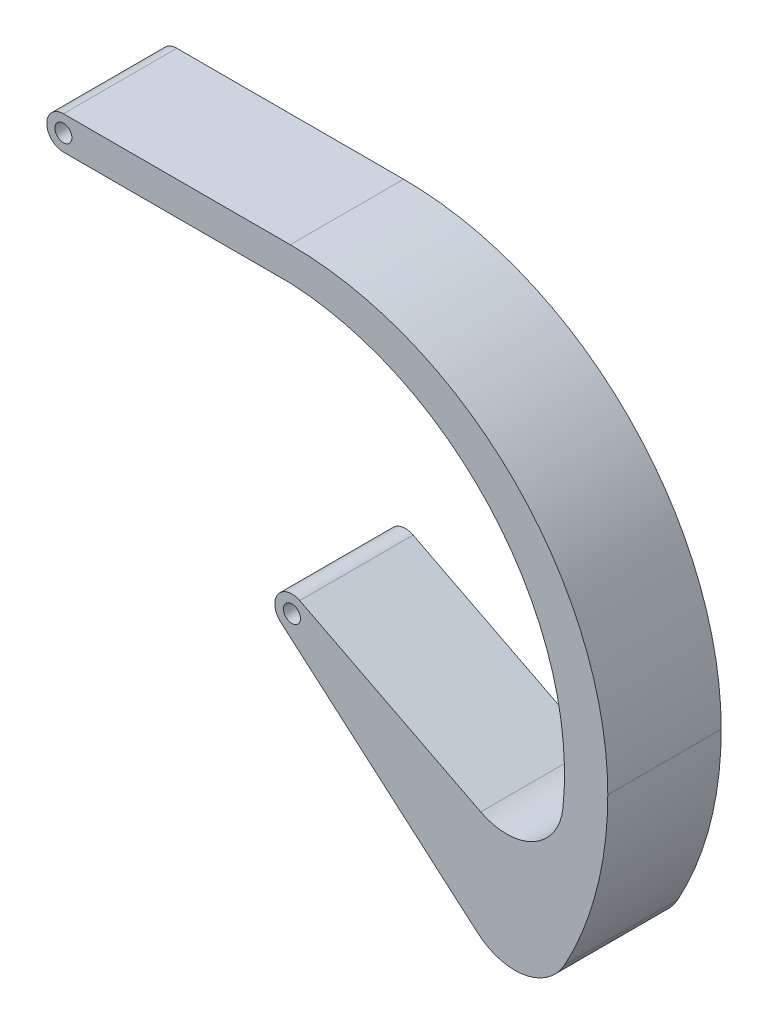
from build123d import *

# Parameters (mm, degrees)
BOSS_EXTRUDE1_DEPTH = 2
SKETCH2_R           = 0.15
CUT_EXTRUDE1_DEPTH  = 3
SKETCH3_R           = 0.15
CUT_EXTRUDE4_DEPTH  = 3
FILLET2_R           = 1
FILLET3_R           = 1
SCALE2_SCALE        = 10


with BuildPart() as part:
    # Sketch1 → Boss-Extrude1 (new body)
    with BuildSketch(Plane.XY):
        with BuildLine():
            Line((-1.517184845, 0.342990579), (2.482815155, 0.342990579))
            ThreePointArc((2.482815155, 0.342990579), (6.442613129, -1.297211446), (8.082815155, -5.257009421))
            ThreePointArc((8.082815155, -5.257009421), (7.70871156, -7.378656338), (6.631523189, -9.244401325))
            Line((6.631523189, -9.244401325), (2.315107728, -5.50575471))
            ThreePointArc((2.315107728, -5.50575471), (2.262391387, -5.108396746), (2.650522581, -5.008264131))
            Line((2.650522581, -5.008264131), (6.955903492, -7.209487065))
            ThreePointArc((6.955903492, -7.209487065), (6.513613709, -2.574091852), (2.482815155, -0.242746306))
            Line((2.482815155, -0.242746306), (-1.517184845, -0.242746306))
            ThreePointArc((-1.517184845, -0.242746306), (-1.810053288, 0.050122136), (-1.517184845, 0.342990579))
        make_face()
    extrude(amount=BOSS_EXTRUDE1_DEPTH)

    # Sketch2 → Cut-Extrude1 (cut, through all)
    with BuildSketch(Plane(origin=(0, 0, 0), x_dir=(-1, 0, 0), z_dir=(0, 0, -1))):
        with Locations((-2.512956146, -5.277330883)):
            Circle(SKETCH2_R)
    extrude(amount=-CUT_EXTRUDE1_DEPTH, mode=Mode.SUBTRACT)

    # Sketch3 → Cut-Extrude4 (cut, through all)
    with BuildSketch(Plane(origin=(0, 0, 0), x_dir=(-1, 0, 0), z_dir=(0, 0, -1))):
        with Locations((1.517184845, 0.050122136)):
            Circle(SKETCH3_R)
    extrude(amount=-CUT_EXTRUDE4_DEPTH, mode=Mode.SUBTRACT)

    # Fillet2
    fillet2_edges = [part.edges().sort_by_distance(p)[0] for p in [
        (6.631523189, -9.244401325, 1),
    ]]
    fillet(fillet2_edges, radius=FILLET2_R)

    # Fillet3
    fillet3_edges = [part.edges().sort_by_distance(p)[0] for p in [
        (6.955903492, -7.209487065, 1),
    ]]
    fillet(fillet3_edges, radius=FILLET3_R)


with BuildPart() as part_1:
    # Scale2: scaled about (5.037716687, -4.281654958, 1)
    add(part.part.scale(SCALE2_SCALE).moved(Location((-45.339450183, 38.534894622, -9))))


solid = part_1.part
